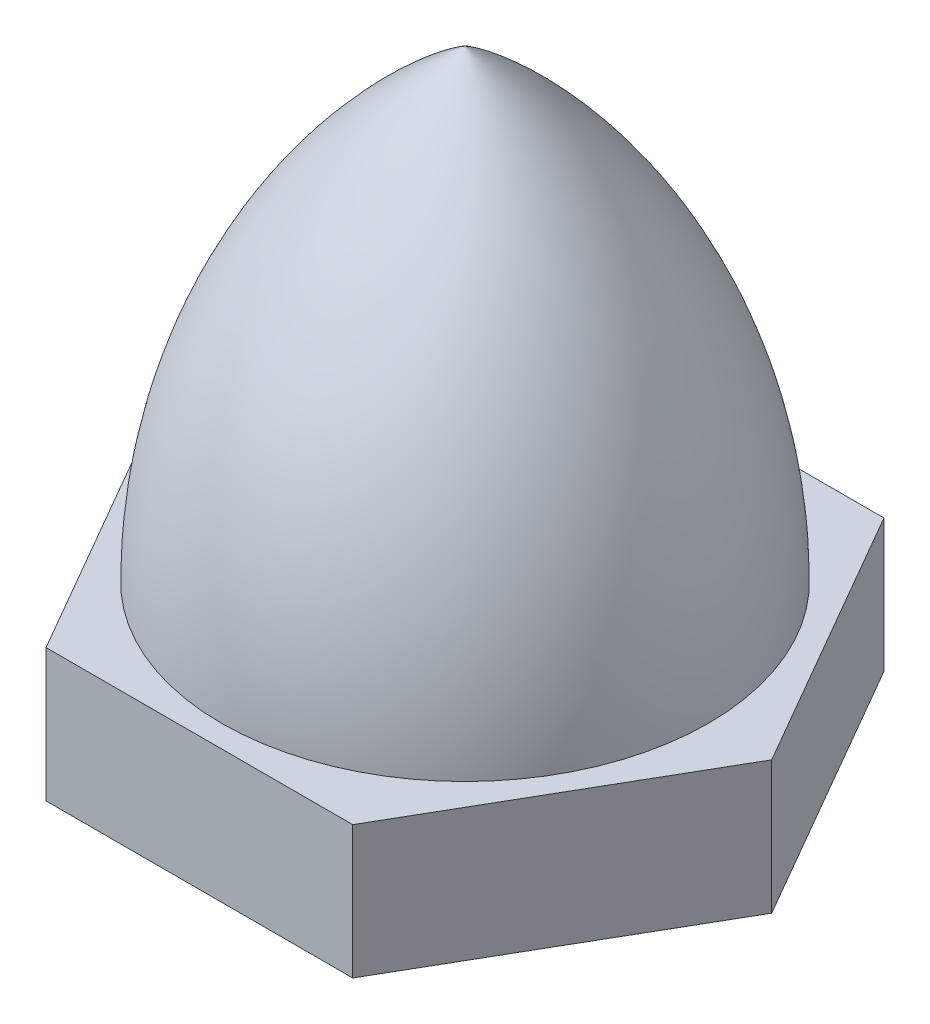
from build123d import *

# Parameters (mm, degrees)
BOSS_EXTRUDE1_DEPTH   = 3
M6_TAPPED_HOLE1_D     = 5
M6_TAPPED_HOLE1_DEPTH = 10
M6_TAPPED_HOLE1_TIP   = 1.502151548


with BuildPart() as part:
    # Sketch1 → Boss-Extrude1 (new body)
    with BuildSketch(Plane(origin=(0, 0, 0), x_dir=(1, 0, 0), z_dir=(0, 1, 0))):
        Polygon((6.92820323, 0), (3.464101615, 6), (-3.464101615, 6), (-6.92820323, 0), (-3.464101615, -6), (3.464101615, -6), align=None)
    extrude(amount=BOSS_EXTRUDE1_DEPTH)

    # Sketch2 → Revolve1 (revolve)
    with BuildSketch(Plane.XY):
        with BuildLine():
            Line((0, 3), (0, 13.5))
            ThreePointArc((0, 13.5), (4.041757337, 8.926634796), (5.5, 3))
            Line((5.5, 3), (0, 3))
        make_face()
    revolve(axis=Axis((0, 3, 0), (0, 1, 0)))

    # M6 Tapped Hole1
    with Locations(Plane(origin=(0, 0, 0), x_dir=(-1, 0, 0), z_dir=(0, -1, 0))):
        with Locations((0, 0)):
            Hole(M6_TAPPED_HOLE1_D / 2, depth=M6_TAPPED_HOLE1_DEPTH)
            with Locations((0, 0, -(M6_TAPPED_HOLE1_DEPTH + M6_TAPPED_HOLE1_TIP / 2))):  # 118° drill point
                Cone(0, M6_TAPPED_HOLE1_D / 2, M6_TAPPED_HOLE1_TIP, mode=Mode.SUBTRACT)


solid = part.part
